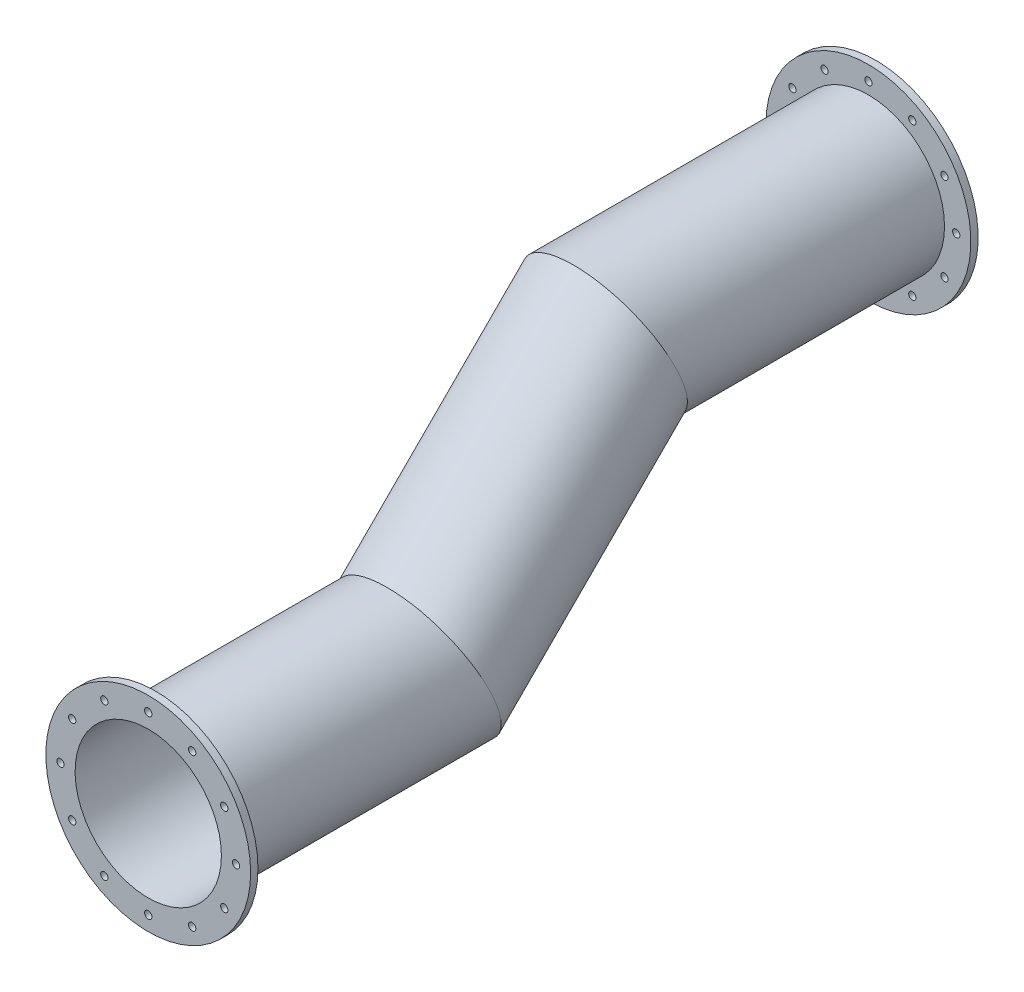
from build123d import *

# Parameters (mm, degrees)
SKETCH2_R           = 52
SKETCH2_R_2         = 50
SKETCH4_R           = 70
SKETCH4_R_2         = 50
SKETCH4_R_3         = 2.5
BOSS_EXTRUDE1_DEPTH = 5
BOSS_EXTRUDE2_START = 5
SKETCH5_R           = 70
SKETCH5_R_2         = 50
SKETCH5_R_3         = 2.5
BOSS_EXTRUDE2_DEPTH = 5


with BuildPart() as part:
    # Sweep-Thin1: sweep along a path in Sketch3
    with BuildLine(Plane(origin=(0, 0, 0), x_dir=(0, 0, -1), z_dir=(1, 0, 0))) as sweep_thin1_path:
        Line((0, 0), (180, 0))
        Line((180, 0), (307.279220614, 127.279220614))
        Line((307.279220614, 127.279220614), (487.279220614, 127.279220614))
    # Sketch2 → Sweep-Thin1 (sweep)
    with BuildSketch(Plane.XY):
        Circle(SKETCH2_R)
        Circle(SKETCH2_R_2, mode=Mode.SUBTRACT)
    sweep(path=sweep_thin1_path.line, transition=Transition.RIGHT)

    # Sketch4 → Boss-Extrude1 (add)
    with BuildSketch(Plane.XY):
        Circle(SKETCH4_R)
        with Locations(Location((0, 0, 0), (0, 0, 90))):
            Circle(SKETCH4_R_2, mode=Mode.SUBTRACT)
        with Locations((0, -60)):
            Circle(SKETCH4_R_3, mode=Mode.SUBTRACT)
        with Locations((-30, -51.961524227)):
            Circle(SKETCH4_R_3, mode=Mode.SUBTRACT)
        with Locations((-51.961524227, -30)):
            Circle(SKETCH4_R_3, mode=Mode.SUBTRACT)
        with Locations((-60, 0)):
            Circle(SKETCH4_R_3, mode=Mode.SUBTRACT)
        with Locations((-51.961524227, 30)):
            Circle(SKETCH4_R_3, mode=Mode.SUBTRACT)
        with Locations((-30, 51.961524227)):
            Circle(SKETCH4_R_3, mode=Mode.SUBTRACT)
        with Locations((0, 60)):
            Circle(SKETCH4_R_3, mode=Mode.SUBTRACT)
        with Locations((30, 51.961524227)):
            Circle(SKETCH4_R_3, mode=Mode.SUBTRACT)
        with Locations((51.961524227, 30)):
            Circle(SKETCH4_R_3, mode=Mode.SUBTRACT)
        with Locations((60, 0)):
            Circle(SKETCH4_R_3, mode=Mode.SUBTRACT)
        with Locations((51.961524227, -30)):
            Circle(SKETCH4_R_3, mode=Mode.SUBTRACT)
        with Locations((30, -51.961524227)):
            Circle(SKETCH4_R_3, mode=Mode.SUBTRACT)
    extrude(amount=BOSS_EXTRUDE1_DEPTH)

    # Sketch5 → Boss-Extrude2 (add)
    with BuildSketch(Plane(origin=(0, 0, -487.279220614), x_dir=(-1, 0, 0), z_dir=(0, 0, -1)).offset(BOSS_EXTRUDE2_START)):
        with Locations((0, 127.279220614)):
            Circle(SKETCH5_R)
        with Locations((0, 127.279220614)):
            Circle(SKETCH5_R_2, mode=Mode.SUBTRACT)
        with Locations((0, 67.279220614)):
            Circle(SKETCH5_R_3, mode=Mode.SUBTRACT)
        with Locations((-30, 75.317696387)):
            Circle(SKETCH5_R_3, mode=Mode.SUBTRACT)
        with Locations((-51.961524227, 97.279220614)):
            Circle(SKETCH5_R_3, mode=Mode.SUBTRACT)
        with Locations((-60, 127.279220614)):
            Circle(SKETCH5_R_3, mode=Mode.SUBTRACT)
        with Locations((-51.961524227, 157.279220614)):
            Circle(SKETCH5_R_3, mode=Mode.SUBTRACT)
        with Locations((-30, 179.240744841)):
            Circle(SKETCH5_R_3, mode=Mode.SUBTRACT)
        with Locations((0, 187.279220614)):
            Circle(SKETCH5_R_3, mode=Mode.SUBTRACT)
        with Locations((30, 179.240744841)):
            Circle(SKETCH5_R_3, mode=Mode.SUBTRACT)
        with Locations((51.961524227, 157.279220614)):
            Circle(SKETCH5_R_3, mode=Mode.SUBTRACT)
        with Locations((60, 127.279220614)):
            Circle(SKETCH5_R_3, mode=Mode.SUBTRACT)
        with Locations((51.961524227, 97.279220614)):
            Circle(SKETCH5_R_3, mode=Mode.SUBTRACT)
        with Locations((30, 75.317696387)):
            Circle(SKETCH5_R_3, mode=Mode.SUBTRACT)
    extrude(amount=-BOSS_EXTRUDE2_DEPTH)


solid = part.part
